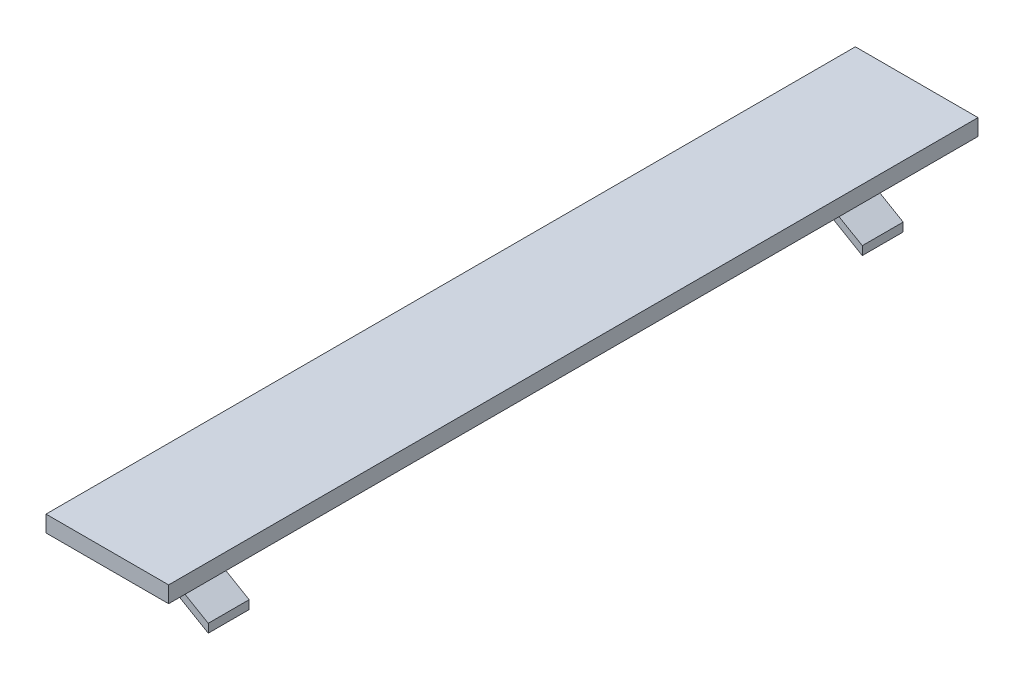
from build123d import *

# Parameters (mm, degrees)
SKETCH_1_W      = 15
SKETCH_1_H      = 99
EXTRUDE_1_DEPTH = 2
EXTRUDE_2_DEPTH = 5
EXTRUDE_3_DEPTH = 5


with BuildPart() as part:
    # 草图1 → 凸台-拉伸1 (new body)
    with BuildSketch(Plane(origin=(0, 0, 0), x_dir=(1, 0, 0), z_dir=(0, 1, 0))):
        with Locations((-2.772511848, -40.347156398)):
            Rectangle(SKETCH_1_W, SKETCH_1_H)
    extrude(amount=EXTRUDE_1_DEPTH)

    # 草图3 → 凸台-拉伸2 (add)
    with BuildSketch(Plane.XY):
        Polygon((-4.810549778, 0), (4.727488152, -5.543936954), (4.727488152, -4.491111673), (-2.999221917, 0), align=None)
    extrude(amount=EXTRUDE_2_DEPTH)

    # 草图5 → 凸台-拉伸3 (add)
    with BuildSketch(Plane.XY.offset(80)):
        Polygon((-4.810549778, 0), (4.727488152, -5.543936954), (4.727488152, -4.491111673), (-2.999221917, 0), align=None)
    extrude(amount=EXTRUDE_3_DEPTH)


solid = part.part
